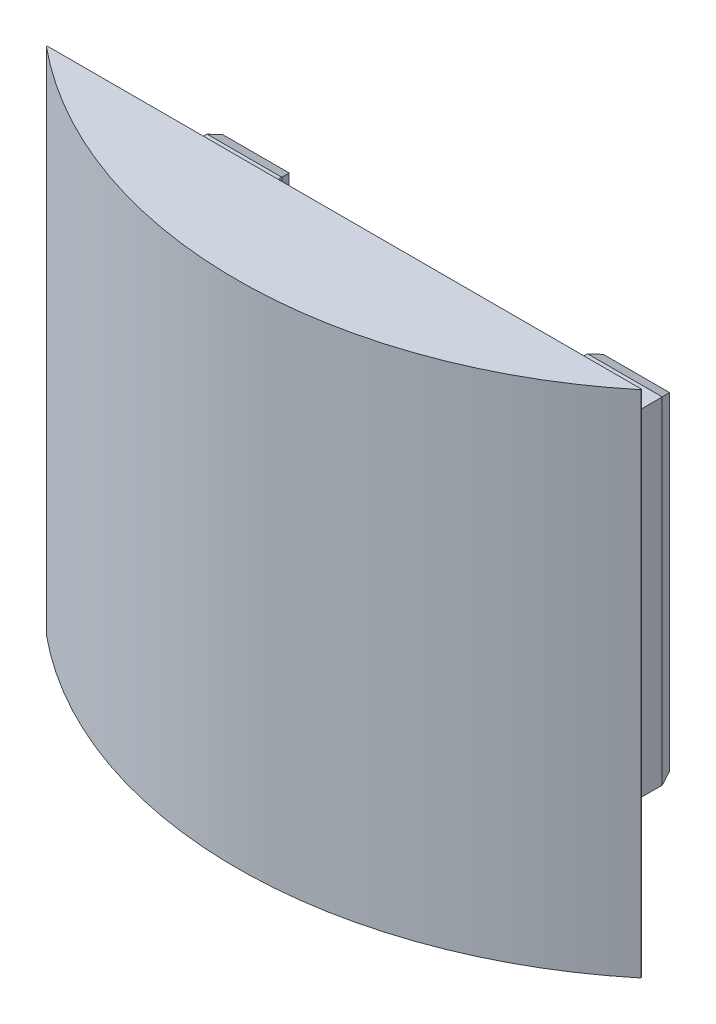
from build123d import *

# Parameters (mm, degrees)
SKETCH2_W             = 53.6
SKETCH2_H             = 39.6
BOSS_EXTRUDE1_DEPTH   = 12
SKETCH3_W             = 70
SKETCH3_H             = 60
BOSS_EXTRUDE2_DEPTH   = 0.1
SKETCH4_R             = 2.1
CUT_EXTRUDE1_DEPTH    = 50.8
SKETCH5_W             = 36
SKETCH5_H             = 39.6
CUT_EXTRUDE2_DEPTH    = 12
CHAMFER1_SIZE         = 0.5
CHAMFER1_SIZE2        = 1.37373871
CHAMFER1_PART_2_SIZE  = 0.5
CHAMFER1_PART_2_SIZE2 = 1.37373871
BOSS_EXTRUDE3_DEPTH   = 60


with BuildPart() as part:
    # Sketch2 → Boss-Extrude1 (new body)
    with BuildSketch(Plane.XY):
        Rectangle(SKETCH2_W, SKETCH2_H)
    extrude(amount=BOSS_EXTRUDE1_DEPTH)

    # Sketch3 → Boss-Extrude2 (add)
    with BuildSketch(Plane.XY.offset(12)):
        Rectangle(SKETCH3_W, SKETCH3_H)
    extrude(amount=BOSS_EXTRUDE2_DEPTH)

    # Sketch4 → Cut-Extrude1 (cut, through all)
    with BuildSketch(Plane(origin=(0, 19.8, 0), x_dir=(1, 0, 0), z_dir=(0, 1, 0))):
        with Locations((22.5, -4.6)):
            Circle(SKETCH4_R)
        with Locations((-22.5, -4.6)):
            Circle(SKETCH4_R)
    extrude(amount=-CUT_EXTRUDE1_DEPTH, mode=Mode.SUBTRACT)

    # Sketch5 → Cut-Extrude2 (cut)
    with BuildSketch(Plane(origin=(0, 0, 0), x_dir=(-1, 0, 0), z_dir=(0, 0, -1))):
        Rectangle(SKETCH5_W, SKETCH5_H)
    extrude(amount=-CUT_EXTRUDE2_DEPTH, mode=Mode.SUBTRACT)

    # Chamfer1
    chamfer1_edges = [part.edges().sort_by_distance(p)[0] for p in [
        (-22.4, 19.8, 0),
        (-18, 0, 0),
        (-22.4, -19.8, 0),
        (-26.8, 0, 0),
    ]]
    chamfer1_side = [part.faces().sort_by_distance(p)[0] for p in [
        (-22.4, 0, 0),
    ]]
    chamfer(chamfer1_edges, length=CHAMFER1_SIZE, length2=CHAMFER1_SIZE2, reference=chamfer1_side[0])

    # Chamfer1 part 2
    chamfer1_part_2_edges = [part.edges().sort_by_distance(p)[0] for p in [
        (22.4, -19.8, 0),
        (18, 0, 0),
        (22.4, 19.8, 0),
        (26.8, 0, 0),
    ]]
    chamfer1_part_2_side = [part.faces().sort_by_distance(p)[0] for p in [
        (22.4, 0, 0),
    ]]
    chamfer(chamfer1_part_2_edges, length=CHAMFER1_PART_2_SIZE, length2=CHAMFER1_PART_2_SIZE2, reference=chamfer1_part_2_side[0])

    # Sketch6 → Boss-Extrude3 (add)
    with BuildSketch(Plane(origin=(0, 30, 0), x_dir=(1, 0, 0), z_dir=(0, 1, 0))):
        with BuildLine():
            Line((35, -12.1), (-35, -12.1))
            ThreePointArc((-35, -12.1), (0, -24.673593129), (35, -12.1))
        make_face()
    extrude(amount=-BOSS_EXTRUDE3_DEPTH)


solid = part.part
